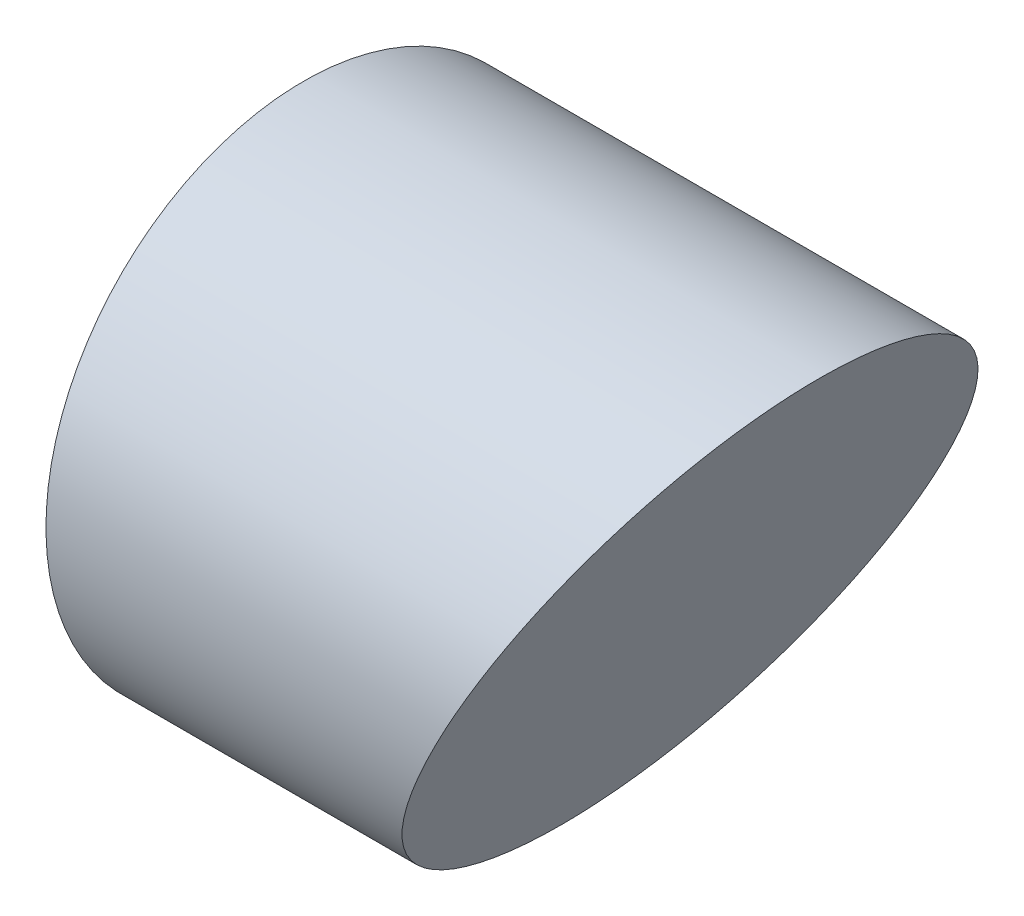
from build123d import *

# Parameters (mm, degrees)
BOSS_EXTRUDE2_DEPTH = 127
SKETCH3_R           = 57.15
CUT_EXTRUDE1_DEPTH  = 62
CUT_EXTRUDE2_DEPTH  = 128


with BuildPart() as part:
    # Sketch2 → Boss-Extrude2 (new body)
    with BuildSketch(Plane.XY):
        Polygon((0, 0), (0, -127), (63.5, -127), (127, 0), align=None)
    extrude(amount=BOSS_EXTRUDE2_DEPTH)

    # Sketch3 → Cut-Extrude1 (cut)
    with BuildSketch(Plane.ZY):
        with Locations((63.5, -63.5)):
            Circle(SKETCH3_R)
    extrude(amount=-CUT_EXTRUDE1_DEPTH, mode=Mode.SUBTRACT)

    # Sketch4 → Cut-Extrude2 (cut, through all)
    with BuildSketch(Plane.ZY):
        with BuildLine():
            Line((127, 0), (63.5, 0))
            ThreePointArc((63.5, 0), (108.401280605, -18.598719395), (127, -63.5))
            Line((127, -63.5), (127, 0))
        make_face()
        with BuildLine():
            Line((63.5, 0), (0, 0))
            Line((0, 0), (0, -63.5))
            ThreePointArc((0, -63.5), (18.598719395, -18.598719395), (63.5, 0))
        make_face()
        with BuildLine():
            ThreePointArc((63.5, -127), (18.598719395, -108.401280605), (0, -63.5))
            Line((0, -63.5), (0, -127))
            Line((0, -127), (63.5, -127))
        make_face()
        with BuildLine():
            Line((127, -127), (127, -63.5))
            ThreePointArc((127, -63.5), (108.401280605, -108.401280605), (63.5, -127))
            Line((63.5, -127), (127, -127))
        make_face()
    extrude(amount=-CUT_EXTRUDE2_DEPTH, mode=Mode.SUBTRACT)


solid = part.part
